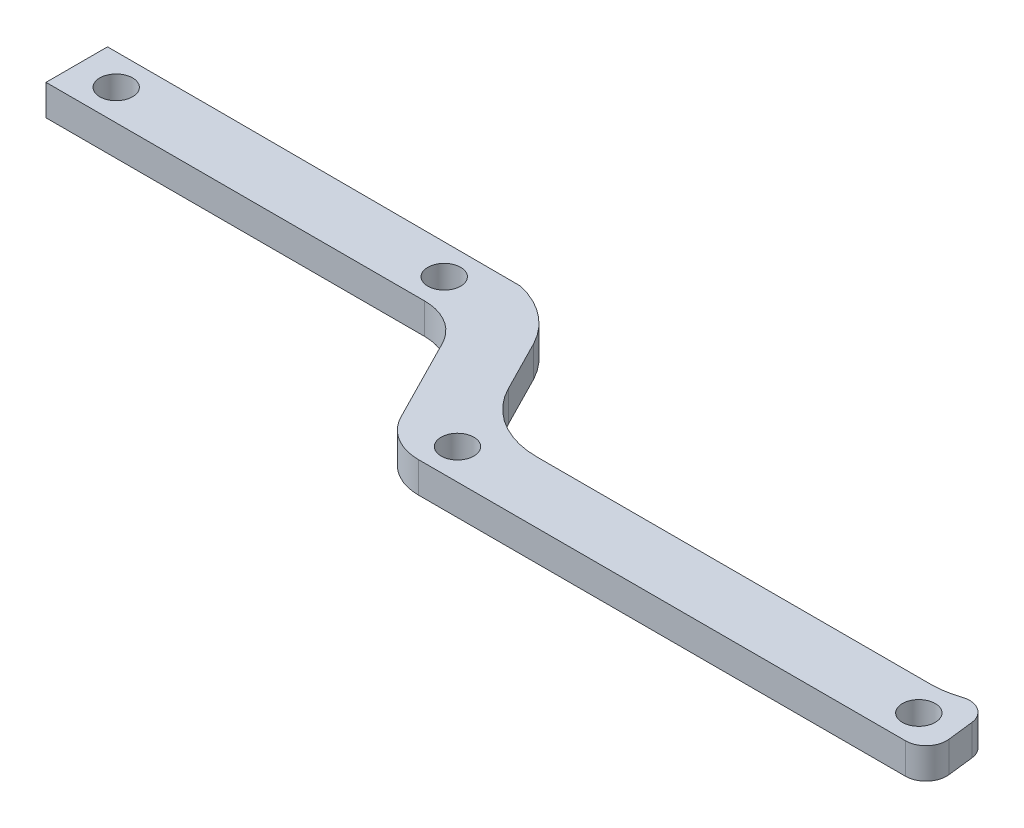
from build123d import *

# Parameters (mm, degrees)
SKETCH_1_R          = 1.6
SKETCH_1_R_2        = 1
SKETCH_1_W          = 24
SKETCH_1_H          = 13
EXTRUDE_1_DEPTH     = 3
SKETCH_2_R          = 1.6
SKETCH_2_W          = 24
SKETCH_2_H          = 10
EXTRUDE_2_DEPTH     = 9
SKETCH_3_R          = 6
CUT_EXTRUDE_1_DEPTH = 20
SKETCH_4_R          = 4
CUT_EXTRUDE_2_DEPTH = 72.704206567
SKETCH_6_R          = 5.6
CUT_EXTRUDE_3_DEPTH = 5
SKETCH_7_R          = 5.6
CUT_EXTRUDE_4_DEPTH = 6
FILLET_5_R          = 5
FILLET_6_R          = 5
CUT_EXTRUDE1_DEPTH  = 13.0000001
FILLET1_R           = 2


with BuildPart() as part:
    # Эскиз1 → Бобышка-Вытянуть1 (new body)
    with BuildSketch(Plane(origin=(0, 0, 0), x_dir=(1, 0, 0), z_dir=(0, 1, 0))):
        with BuildLine():
            Line((-59.846473334, -34), (-49.887758312, 18))
            Line((-49.887758312, 18), (36.612736258, 18))
            Line((36.612736258, 18), (75.112241688, 5.920216985))
            Line((75.112241688, 5.920216985), (75.112241688, -16.079783015))
            Line((75.112241688, -16.079783015), (41.245672077, -52.430849732))
            ThreePointArc((41.245672077, -52.430849732), (39.914841322, -53.372078747), (38.318998701, -53.704206567))
            Line((38.318998701, -53.704206567), (-9.799827382, -53.704206567))
            ThreePointArc((-9.799827382, -53.704206567), (-12.412320205, -52.967407389), (-14.254860003, -50.974159066))
            Line((-14.254860003, -50.974159066), (-19.846473334, -40))
            Line((-19.846473334, -40), (-59.846473334, -40))
            Line((-59.846473334, -40), (-59.846473334, -34))
        make_face()
        with Locations((-8, 14)):
            Circle(SKETCH_1_R, mode=Mode.SUBTRACT)
        with Locations((8, 14)):
            Circle(SKETCH_1_R, mode=Mode.SUBTRACT)
        with Locations((-8, -16)):
            Circle(SKETCH_1_R, mode=Mode.SUBTRACT)
        with Locations((8, -16)):
            Circle(SKETCH_1_R, mode=Mode.SUBTRACT)
        with Locations((-47, 14)):
            Circle(SKETCH_1_R, mode=Mode.SUBTRACT)
        with Locations((70, 2)):
            Circle(SKETCH_1_R, mode=Mode.SUBTRACT)
        with Locations((50, 2)):
            Circle(SKETCH_1_R, mode=Mode.SUBTRACT)
        with Locations((18, 14)):
            Circle(SKETCH_1_R, mode=Mode.SUBTRACT)
        with Locations((-47, -16)):
            Circle(SKETCH_1_R, mode=Mode.SUBTRACT)
        with Locations((-56, -37)):
            Circle(SKETCH_1_R, mode=Mode.SUBTRACT)
        with Locations((-24, -37)):
            Circle(SKETCH_1_R, mode=Mode.SUBTRACT)
        with Locations((50, -16)):
            Circle(SKETCH_1_R, mode=Mode.SUBTRACT)
        with Locations((70, -16)):
            Circle(SKETCH_1_R, mode=Mode.SUBTRACT)
        with Locations((-9, -50.704206567)):
            Circle(SKETCH_1_R, mode=Mode.SUBTRACT)
        with Locations((36, -50.704206567)):
            Circle(SKETCH_1_R, mode=Mode.SUBTRACT)
        with Locations((60, -7)):
            Circle(SKETCH_1_R, mode=Mode.SUBTRACT)
        with Locations((-42, -8)):
            Circle(SKETCH_1_R_2, mode=Mode.SUBTRACT)
        with Locations((-14, -8)):
            Circle(SKETCH_1_R_2, mode=Mode.SUBTRACT)
        with Locations((-42, 8)):
            Circle(SKETCH_1_R_2, mode=Mode.SUBTRACT)
        with Locations((-14, 8)):
            Circle(SKETCH_1_R_2, mode=Mode.SUBTRACT)
        with Locations((14, 0)):
            Circle(SKETCH_1_R_2, mode=Mode.SUBTRACT)
        with Locations((42, 0)):
            Circle(SKETCH_1_R_2, mode=Mode.SUBTRACT)
        with Locations((28, 0)):
            Rectangle(SKETCH_1_W, SKETCH_1_H, mode=Mode.SUBTRACT)
        with Locations((-28, 8)):
            Rectangle(SKETCH_1_W, SKETCH_1_H, mode=Mode.SUBTRACT)
        with Locations((-28, -8)):
            Rectangle(SKETCH_1_W, SKETCH_1_H, mode=Mode.SUBTRACT)
        with BuildLine():
            Line((-47.677053254, -24.900709984), (-49.000145857, -34))
            Line((-49.000145857, -34), (-22.297676486, -34))
            Line((-22.297676486, -34), (-19.846473334, -34))
            ThreePointArc((-19.846473334, -34), (-16.425778662, -35.467187694), (-13.988679802, -38.280431537))
            Line((-13.988679802, -38.280431537), (-11.413907263, -43.333707171))
            ThreePointArc((-11.413907263, -43.333707171), (-8.465843587, -46.522904488), (-4.28585507, -47.701783173))
            Line((-4.28585507, -47.701783173), (34.165827616, -47.701783173))
            ThreePointArc((34.165827616, -47.701783173), (37.877016972, -46.788889321), (40.741225842, -44.258551563))
            Line((40.741225842, -44.258551563), (51.02606102, -29.417576293))
            ThreePointArc((51.02606102, -29.417576293), (51.409841961, -23.216607983), (46.09451235, -20))
            Line((46.09451235, -20), (-41.778616049, -20))
            ThreePointArc((-41.778616049, -20), (-45.612951708, -21.385038456), (-47.677053254, -24.900709984))
        make_face(mode=Mode.SUBTRACT)
    extrude(amount=EXTRUDE_1_DEPTH)

    # Эскиз2 → Бобышка-Вытянуть2 (add)
    with BuildSketch(Plane(origin=(0, 0, 0), x_dir=(1, 0, 0), z_dir=(0, 1, 0))):
        Polygon((46.101706289, 15.022696844), (46.09451235, -20), (71.459960933, -20), (75.112241688, -16.079783015), (75.112241688, 5.920216985), align=None)
        with Locations((50, 2)):
            Circle(SKETCH_2_R, mode=Mode.SUBTRACT)
        with Locations((70, 2)):
            Circle(SKETCH_2_R, mode=Mode.SUBTRACT)
        with Locations((70, -16)):
            Circle(SKETCH_2_R, mode=Mode.SUBTRACT)
        with Locations((50, -16)):
            Circle(SKETCH_2_R, mode=Mode.SUBTRACT)
        with Locations((60, -7)):
            Circle(SKETCH_2_R, mode=Mode.SUBTRACT)
        with Locations((0, 13)):
            Rectangle(SKETCH_2_W, SKETCH_2_H)
        with Locations((-8, 14)):
            Circle(SKETCH_2_R, mode=Mode.SUBTRACT)
        with Locations((8, 14)):
            Circle(SKETCH_2_R, mode=Mode.SUBTRACT)
        with Locations((0, -14.961092538)):
            Rectangle(SKETCH_2_W, SKETCH_2_H)
        with Locations((-8, -16)):
            Circle(SKETCH_2_R, mode=Mode.SUBTRACT)
        with Locations((8, -16)):
            Circle(SKETCH_2_R, mode=Mode.SUBTRACT)
    extrude(amount=-EXTRUDE_2_DEPTH)

    # Эскиз3 → Вырез-Вытянуть1 (cut)
    with BuildSketch(Plane(origin=(75.112241688, 0, 0), x_dir=(0, 0, -1), z_dir=(1, 0, 0))):
        with Locations((-7.384625177, -9)):
            Circle(SKETCH_3_R)
    extrude(amount=-CUT_EXTRUDE_1_DEPTH, mode=Mode.SUBTRACT)

    # Эскиз4 → Вырез-Вытянуть2 (cut, through all)
    with BuildSketch(Plane(origin=(0, 0, -18), x_dir=(-1, 0, 0), z_dir=(0, 0, -1))):
        with Locations((0, -9)):
            Circle(SKETCH_4_R)
    extrude(amount=-CUT_EXTRUDE_2_DEPTH, mode=Mode.SUBTRACT)

    # Эскиз6 → Вырез-Вытянуть3 (cut)
    with BuildSketch(Plane(origin=(0, 0, -18), x_dir=(-1, 0, 0), z_dir=(0, 0, -1))):
        with Locations((0, -9)):
            Circle(SKETCH_6_R)
    extrude(amount=-CUT_EXTRUDE_3_DEPTH, mode=Mode.SUBTRACT)

    # Эскиз7 → Вырез-Вытянуть4 (cut)
    with BuildSketch(Plane.XY.offset(19.961092538)):
        with Locations((0, -9)):
            Circle(SKETCH_7_R)
    extrude(amount=-CUT_EXTRUDE_4_DEPTH, mode=Mode.SUBTRACT)

    # Скругление5
    fillet_5_edges = [part.edges().sort_by_distance(p)[0] for p in [
        (-49.887758312, 1.5, -18),
    ]]
    fillet(fillet_5_edges, radius=FILLET_5_R)

    # Скругление6
    fillet_6_edges = [part.edges().sort_by_distance(p)[0] for p in [
        (-19.846473334, 1.5, 40),
    ]]
    fillet(fillet_6_edges, radius=FILLET_6_R)

    # Sketch1 → Cut-Extrude1 (cut, through all)
    with BuildSketch(Plane(origin=(0, 3, 0), x_dir=(1, 0, 0), z_dir=(0, 1, 0))):
        with BuildLine():
            Line((-59.846473334, -34), (-49.000145857, -34))
            Line((-49.000145857, -34), (39.05274243, -34.20975492))
            Line((39.05274243, -34.20975492), (39.05274243, -46.035665363))
            Line((39.05274243, -46.035665363), (39.914841322, -53.372078747))
            ThreePointArc((39.914841322, -53.372078747), (27.574901916, 149.639179971), (-59.846473334, -34))
        make_face()
    extrude(amount=-CUT_EXTRUDE1_DEPTH, mode=Mode.SUBTRACT)

    # Fillet1
    fillet1_edges = [part.edges().sort_by_distance(p)[0] for p in [
        (39.914841322, 1.5, 53.372078747),
        (39.05274243, 1.5, 46.035665363),
    ]]
    fillet(fillet1_edges, radius=FILLET1_R)


solid = part.part
